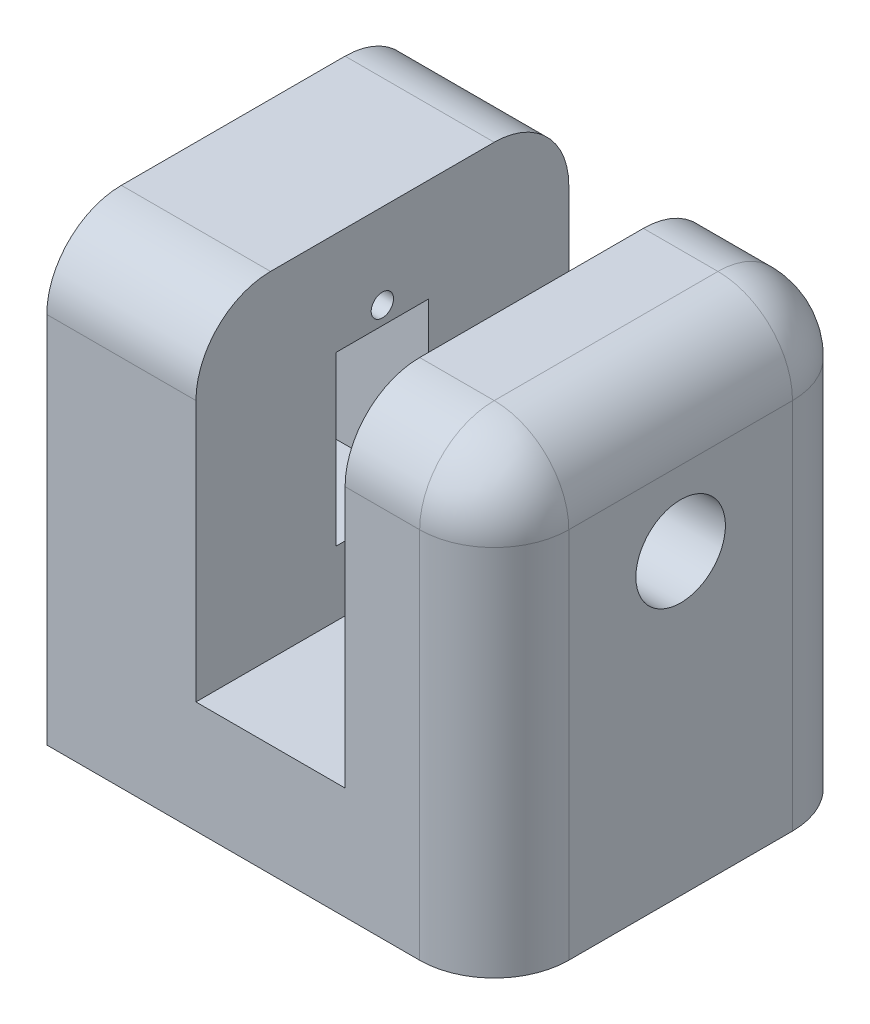
from build123d import *

# Parameters (mm, degrees)
SKETCH1_W           = 60
SKETCH1_H           = 50
BOSS_EXTRUDE1_DEPTH = 15
SKETCH5_W           = 20
SKETCH5_H           = 50
BOSS_EXTRUDE5_DEPTH = 45
SKETCH6_R           = 6
CUT_EXTRUDE1_DEPTH  = 84
SKETCH7_R           = 2.5
CUT_EXTRUDE2_DEPTH  = 19
FILLET1_R           = 10
FILLET3_R           = 10
SKETCH8_R           = 6
SKETCH8_R_2         = 1.5
CUT_EXTRUDE3_DEPTH  = 30


with BuildPart() as part:
    # Sketch1 → Boss-Extrude1 (new body)
    with BuildSketch(Plane(origin=(0, 0, 0), x_dir=(1, 0, 0), z_dir=(0, 1, 0))):
        with Locations((30, -25)):
            Rectangle(SKETCH1_W, SKETCH1_H)
    extrude(amount=BOSS_EXTRUDE1_DEPTH)

    # Sketch5 → Boss-Extrude5 (add)
    with BuildSketch(Plane(origin=(0, 15, 0), x_dir=(1, 0, 0), z_dir=(0, 1, 0))):
        with Locations((10, -25)):
            Rectangle(SKETCH5_W, SKETCH5_H)
        with Locations((50, -25)):
            Rectangle(SKETCH5_W, SKETCH5_H)
    extrude(amount=BOSS_EXTRUDE5_DEPTH)

    # Sketch6 → Cut-Extrude1 (cut)
    with BuildSketch(Plane.ZY):
        with Locations((25, 40)):
            Circle(SKETCH6_R)
    extrude(amount=-CUT_EXTRUDE1_DEPTH, mode=Mode.SUBTRACT)

    # Sketch7 → Cut-Extrude2 (cut)
    with BuildSketch(Plane.XZ):
        with Locations((30, 25)):
            Circle(SKETCH7_R)
    extrude(amount=-CUT_EXTRUDE2_DEPTH, mode=Mode.SUBTRACT)

    # Fillet1
    fillet1_edges = [part.edges().sort_by_distance(p)[0] for p in [
        (10, 60, 50),
        (10, 60, 0),
        (50, 60, 0),
        (50, 60, 50),
    ]]
    fillet(fillet1_edges, radius=FILLET1_R)

    # Fillet3
    fillet3_edges = [part.edges().sort_by_distance(p)[0] for p in [
        (60, 25, 50),
        (60, 60, 25),
        (60, 25, 0),
        (60, 57.071067812, 2.928932188),
        (60, 57.071067812, 47.071067812),
    ]]
    fillet(fillet3_edges, radius=FILLET3_R)

    # Sketch8 → Cut-Extrude3 (cut)
    with BuildSketch(Plane.ZY):
        Polygon((31.2, 46.2), (25, 46.2), (18.8, 46.2), (18.8, 23.7), (25, 23.7), (31.2, 23.7), align=None)
        with Locations((25, 40)):
            Circle(SKETCH8_R, mode=Mode.SUBTRACT)
        with Locations((25, 48.6)):
            Circle(SKETCH8_R_2)
        with Locations((25, 21.3)):
            Circle(SKETCH8_R_2)
    extrude(amount=-CUT_EXTRUDE3_DEPTH, mode=Mode.SUBTRACT)


solid = part.part
